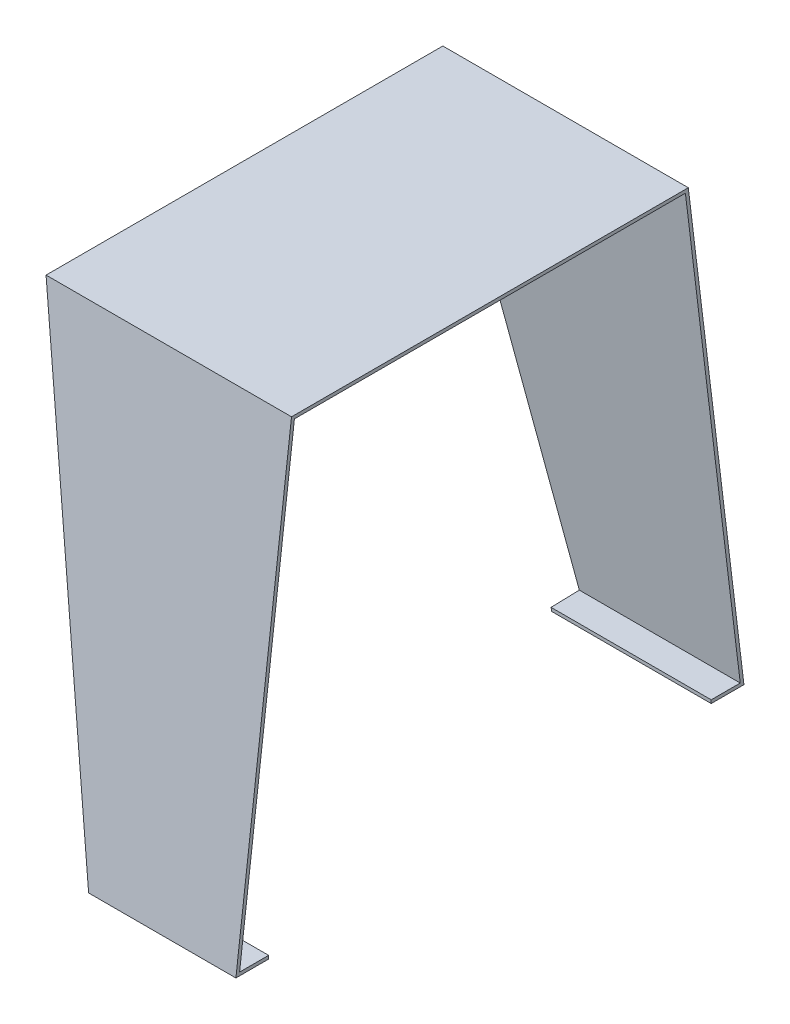
from build123d import *

# Parameters (mm, degrees)
EXTRUDE_1_DEPTH     = 150
CUT_EXTRUDE_1_DEPTH = 309.196154086
CUT_EXTRUDE_3_REACH = 4
SKETCH_3_W          = 150
SKETCH_3_H          = 270.46


with BuildPart() as part:
    # 草图1 → 凸台-拉伸1 (new body)
    with BuildSketch(Plane(origin=(0, 0, 0), x_dir=(0, 0, -1), z_dir=(1, 0, 0))):
        Polygon((0, 0), (-34, -280), (276.46, -280), (242.46, 0), align=None)
        Polygon((240.688166201, -2), (1.771833799, -2), (-31.742451915, -278), (274.202451915, -278), align=None, mode=Mode.SUBTRACT)
    extrude(amount=EXTRUDE_1_DEPTH)

    # 草图2 → 切除-拉伸1 (cut, through all)
    with BuildSketch(Plane(origin=(0, 0, 0), x_dir=(1, 0, 0), z_dir=(0, 0.120543125, 0.992708091))):
        Polygon((0, 0), (0, -282.056731882), (60, -282.056731882), align=None)
    extrude(amount=-CUT_EXTRUDE_1_DEPTH, mode=Mode.SUBTRACT)

    # 草图3 → 切除-拉伸3 (cut, up to next)
    with BuildSketch(Plane(origin=(0, -278, 0), x_dir=(1, 0, 0), z_dir=(0, 1, 0)), mode=Mode.PRIVATE) as cut_extrude_3_sk1:
        with Locations((75, 121.23)):
            Rectangle(SKETCH_3_W, SKETCH_3_H)
    cut_extrude_3_tool1 = extrude(cut_extrude_3_sk1.sketch, amount=-CUT_EXTRUDE_3_REACH, mode=Mode.PRIVATE) & part.part
    add(cut_extrude_3_tool1.solids().sort_by_distance((75, -278, -121.23))[0], mode=Mode.SUBTRACT)


solid = part.part
